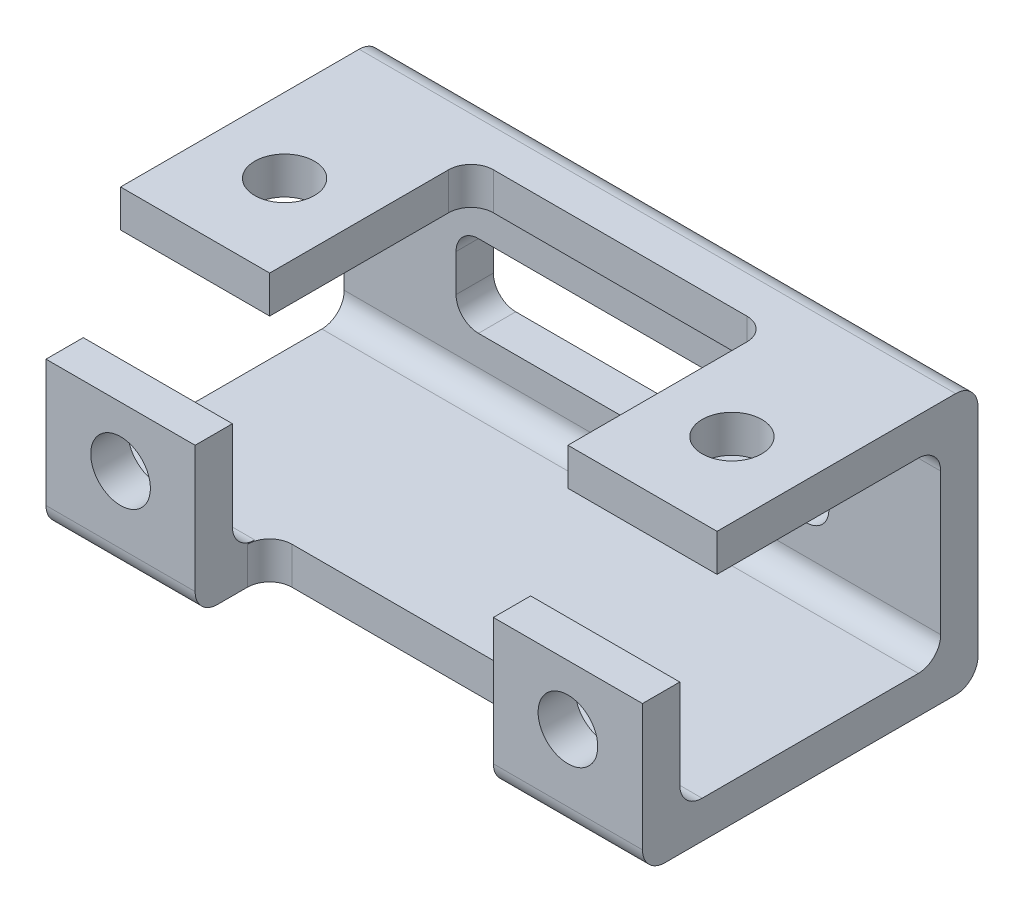
from build123d import *

# Parameters (mm, degrees)
SKETCH1_W                     = 80
SKETCH1_H                     = 35
RECTANGLE_BLOCK_EXTRUDE_DEPTH = 45
HOLLOW_OUT_BLOCK_CUT_DEPTH    = 81
OPEN_CORNER_CUT_DEPTH         = 81
TOP_CUTS_REACH                = 37
SKETCH15_R                    = 4
CIRCLE_CUT_ON_FRONT_REACH     = 12
SKETCH18_R                    = 4
RECTANGLE_CUT_ON_BACK_DEPTH   = 5
CUT_EXTRUDE17_DEPTH           = 81
SKETCH25_W                    = 40
SKETCH25_H                    = 3
SKETCH25_H_2                  = 17
CUT_EXTRUDE18_DEPTH           = 10
BOSS_EXTRUDE6_DEPTH           = 5


with BuildPart() as part:
    # Sketch1 → Rectangle Block Extrude (new body)
    with BuildSketch(Plane.XY):
        Rectangle(SKETCH1_W, SKETCH1_H)
    extrude(amount=RECTANGLE_BLOCK_EXTRUDE_DEPTH)

    # Sketch11 → Hollow Out Block Cut (cut, through all)
    with BuildSketch(Plane.ZY.offset(40)):
        with BuildLine():
            Line((8, 12.5), (37, 12.5))
            ThreePointArc((37, 12.5), (39.121320344, 11.621320344), (40, 9.5))
            Line((40, 9.5), (40, -9.5))
            ThreePointArc((40, -9.5), (39.121320344, -11.621320344), (37, -12.5))
            Line((37, -12.5), (8, -12.5))
            ThreePointArc((8, -12.5), (5.878679656, -11.621320344), (5, -9.5))
            Line((5, -9.5), (5, 9.5))
            ThreePointArc((5, 9.5), (5.878679656, 11.621320344), (8, 12.5))
        make_face()
    extrude(amount=-HOLLOW_OUT_BLOCK_CUT_DEPTH, mode=Mode.SUBTRACT)

    # Sketch12 → Open Corner Cut (cut, through all)
    with BuildSketch(Plane.ZY.offset(40)):
        with BuildLine():
            Line((35, 17.5), (35, 12.5))
            Line((35, 12.5), (37, 12.5))
            ThreePointArc((37, 12.5), (39.121320344, 11.621320344), (40, 9.5))
            Line((40, 9.5), (40, 2.5))
            Line((40, 2.5), (45, 2.5))
            Line((45, 2.5), (45, 17.5))
            Line((45, 17.5), (35, 17.5))
        make_face()
    extrude(amount=-OPEN_CORNER_CUT_DEPTH, mode=Mode.SUBTRACT)

    # Sketch15 → Top Cuts (cut, up to next)
    with BuildSketch(Plane(origin=(0, 17.5, 0), x_dir=(1, 0, 0), z_dir=(0, 1, 0)), mode=Mode.PRIVATE) as top_cuts_sk1:
        with BuildLine():
            Line((17, -8), (-17, -8))
            ThreePointArc((-17, -8), (-19.121320344, -8.878679656), (-20, -11))
            Line((-20, -11), (-20, -35))
            Line((-20, -35), (20, -35))
            Line((20, -35), (20, -11))
            ThreePointArc((20, -11), (19.121320344, -8.878679656), (17, -8))
        make_face()
    top_cuts_tool1 = extrude(top_cuts_sk1.sketch, amount=-TOP_CUTS_REACH, mode=Mode.PRIVATE) & part.part
    add(top_cuts_tool1.solids().sort_by_distance((0, 17.5, 21.546053))[0], mode=Mode.SUBTRACT)
    # Sketch15 → Top Cuts (cut, up to next)
    with BuildSketch(Plane(origin=(0, 17.5, 0), x_dir=(1, 0, 0), z_dir=(0, 1, 0)), mode=Mode.PRIVATE) as top_cuts_sk2:
        with Locations((-30, -23)):
            Circle(SKETCH15_R)
    top_cuts_tool2 = extrude(top_cuts_sk2.sketch, amount=-TOP_CUTS_REACH, mode=Mode.PRIVATE) & part.part
    add(top_cuts_tool2.solids().sort_by_distance((-30, 17.5, 23))[0], mode=Mode.SUBTRACT)
    # Sketch15 → Top Cuts (cut, up to next)
    with BuildSketch(Plane(origin=(0, 17.5, 0), x_dir=(1, 0, 0), z_dir=(0, 1, 0)), mode=Mode.PRIVATE) as top_cuts_sk3:
        with Locations((30, -23)):
            Circle(SKETCH15_R)
    top_cuts_tool3 = extrude(top_cuts_sk3.sketch, amount=-TOP_CUTS_REACH, mode=Mode.PRIVATE) & part.part
    add(top_cuts_tool3.solids().sort_by_distance((30, 17.5, 23))[0], mode=Mode.SUBTRACT)

    # Sketch18 → Circle Cut on Front (cut, up to next)
    with BuildSketch(Plane.XY.offset(35), mode=Mode.PRIVATE) as circle_cut_on_front_sk1:
        with Locations((-30, -5.5)):
            Circle(SKETCH18_R)
    circle_cut_on_front_tool1 = extrude(circle_cut_on_front_sk1.sketch, amount=CIRCLE_CUT_ON_FRONT_REACH, mode=Mode.PRIVATE) & part.part
    add(circle_cut_on_front_tool1.solids().sort_by_distance((-30, -5.5, 35))[0], mode=Mode.SUBTRACT)
    # Sketch18 → Circle Cut on Front (cut, up to next)
    with BuildSketch(Plane.XY.offset(35), mode=Mode.PRIVATE) as circle_cut_on_front_sk2:
        with Locations((30, -5.5)):
            Circle(SKETCH18_R)
    circle_cut_on_front_tool2 = extrude(circle_cut_on_front_sk2.sketch, amount=CIRCLE_CUT_ON_FRONT_REACH, mode=Mode.PRIVATE) & part.part
    add(circle_cut_on_front_tool2.solids().sort_by_distance((30, -5.5, 35))[0], mode=Mode.SUBTRACT)

    # Sketch23 → Rectangle Cut on Back (cut)
    with BuildSketch(Plane(origin=(0, 0, 0), x_dir=(-1, 0, 0), z_dir=(0, 0, -1))):
        with BuildLine():
            Line((22, 5.5), (-22, 5.5))
            ThreePointArc((-22, 5.5), (-24.121320344, 4.621320344), (-25, 2.5))
            Line((-25, 2.5), (-25, -2.5))
            ThreePointArc((-25, -2.5), (-24.121320344, -4.621320344), (-22, -5.5))
            Line((-22, -5.5), (22, -5.5))
            ThreePointArc((22, -5.5), (24.121320344, -4.621320344), (25, -2.5))
            Line((25, -2.5), (25, 2.5))
            ThreePointArc((25, 2.5), (24.121320344, 4.621320344), (22, 5.5))
        make_face()
    extrude(amount=-RECTANGLE_CUT_ON_BACK_DEPTH, mode=Mode.SUBTRACT)

    # Sketch24 → Cut-Extrude17 (cut, through all)
    with BuildSketch(Plane.ZY.offset(40)):
        with BuildLine():
            Line((3, -17.5), (0, -17.5))
            Line((0, -17.5), (0, -14.5))
            ThreePointArc((0, -14.5), (0.878679656, -16.621320344), (3, -17.5))
        make_face()
        with BuildLine():
            Line((0, 14.5), (0, 17.5))
            Line((0, 17.5), (3, 17.5))
            ThreePointArc((3, 17.5), (0.878679656, 16.621320344), (0, 14.5))
        make_face()
        with BuildLine():
            Line((42, -17.5), (45, -17.5))
            Line((45, -17.5), (45, -14.5))
            ThreePointArc((45, -14.5), (44.121320344, -16.621320344), (42, -17.5))
        make_face()
    extrude(amount=-CUT_EXTRUDE17_DEPTH, mode=Mode.SUBTRACT)

    # Sketch25 → Cut-Extrude18 (cut)
    with BuildSketch(Plane.XY.offset(45)):
        with Locations((0, -16)):
            Rectangle(SKETCH25_W, SKETCH25_H)
        with Locations((0, -6)):
            Rectangle(SKETCH25_W, SKETCH25_H_2)
    extrude(amount=-CUT_EXTRUDE18_DEPTH, mode=Mode.SUBTRACT)

    # Sketch28 → Boss-Extrude6 (add)
    with BuildSketch(Plane(origin=(0, -17.5, 0), x_dir=(-1, 0, 0), z_dir=(0, -1, 0))):
        with BuildLine():
            Line((-20, -38), (-20, -35))
            Line((-20, -35), (-17, -35))
            ThreePointArc((-17, -35), (-19.121320344, -35.878679656), (-20, -38))
        make_face()
        with BuildLine():
            Line((20, -38), (20, -35))
            Line((20, -35), (17, -35))
            ThreePointArc((17, -35), (19.121320344, -35.878679656), (20, -38))
        make_face()
    extrude(amount=-BOSS_EXTRUDE6_DEPTH)


solid = part.part
